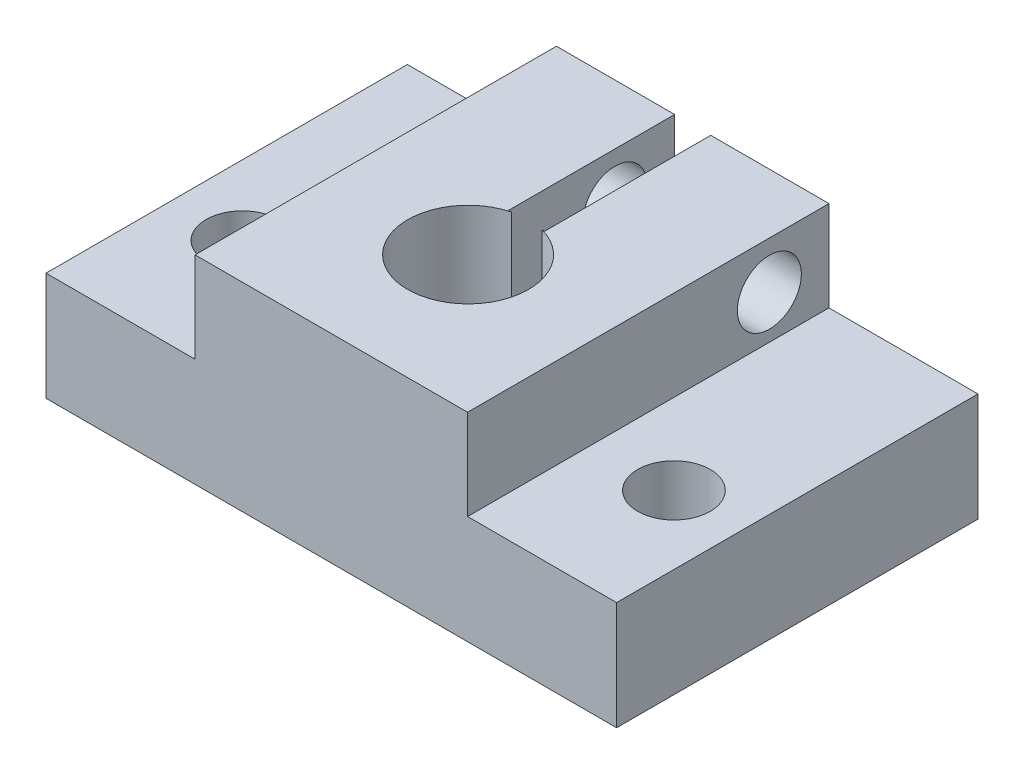
from build123d import *

# Parameters (mm, degrees)
BOSS_EXTRUDE1_DEPTH = 25.4
SKETCH6_R           = 4.25
CUT_EXTRUDE1_DEPTH  = 14.97
SKETCH12_R          = 2.5527
CUT_EXTRUDE2_DEPTH  = 8.62
CUT_EXTRUDE3_DEPTH  = 14.97
SKETCH16_R          = 2.249932
CUT_EXTRUDE8_DEPTH  = 30.62966793


with BuildPart() as part:
    # Sketch1 → Boss-Extrude1 (new body)
    with BuildSketch(Plane.XY):
        Polygon((-20.052587871, 0), (-20.052587871, 7.62), (-9.577080059, 7.62), (-9.577080059, 13.97), (9.577080059, 13.97), (9.577080059, 7.62), (20.052587871, 7.62), (20.052587871, 0), align=None)
    extrude(amount=BOSS_EXTRUDE1_DEPTH)

    # Sketch6 → Cut-Extrude1 (cut, through all)
    with BuildSketch(Plane(origin=(0, 13.97, 0), x_dir=(1, 0, 0), z_dir=(0, 1, 0))):
        with Locations((0, -15.788153465)):
            Circle(SKETCH6_R)
    extrude(amount=-CUT_EXTRUDE1_DEPTH, mode=Mode.SUBTRACT)

    # Sketch12 → Cut-Extrude2 (cut, through all)
    with BuildSketch(Plane(origin=(0, 7.62, 0), x_dir=(1, 0, 0), z_dir=(0, 1, 0))):
        with Locations((-15.141300214, -16.51)):
            Circle(SKETCH12_R)
        with Locations((15.24, -16.556540888)):
            Circle(SKETCH12_R)
    extrude(amount=-CUT_EXTRUDE2_DEPTH, mode=Mode.SUBTRACT)

    # Sketch14 → Cut-Extrude3 (cut, through all)
    with BuildSketch(Plane(origin=(0, 13.97, 0), x_dir=(1, 0, 0), z_dir=(0, 1, 0))):
        Polygon((-1.27, 0), (1.27, 0), (1.27, -11.699930965), (0, -11.538153465), (-1.27, -11.699930965), align=None)
    extrude(amount=-CUT_EXTRUDE3_DEPTH, mode=Mode.SUBTRACT)

    # Sketch16 → Cut-Extrude8 (cut, through all)
    with BuildSketch(Plane(origin=(9.577080059, 0, 0), x_dir=(0, 0, -1), z_dir=(1, 0, 0))):
        with Locations((-4.189047087, 10.668)):
            Circle(SKETCH16_R)
    extrude(amount=-CUT_EXTRUDE8_DEPTH, mode=Mode.SUBTRACT)


solid = part.part
